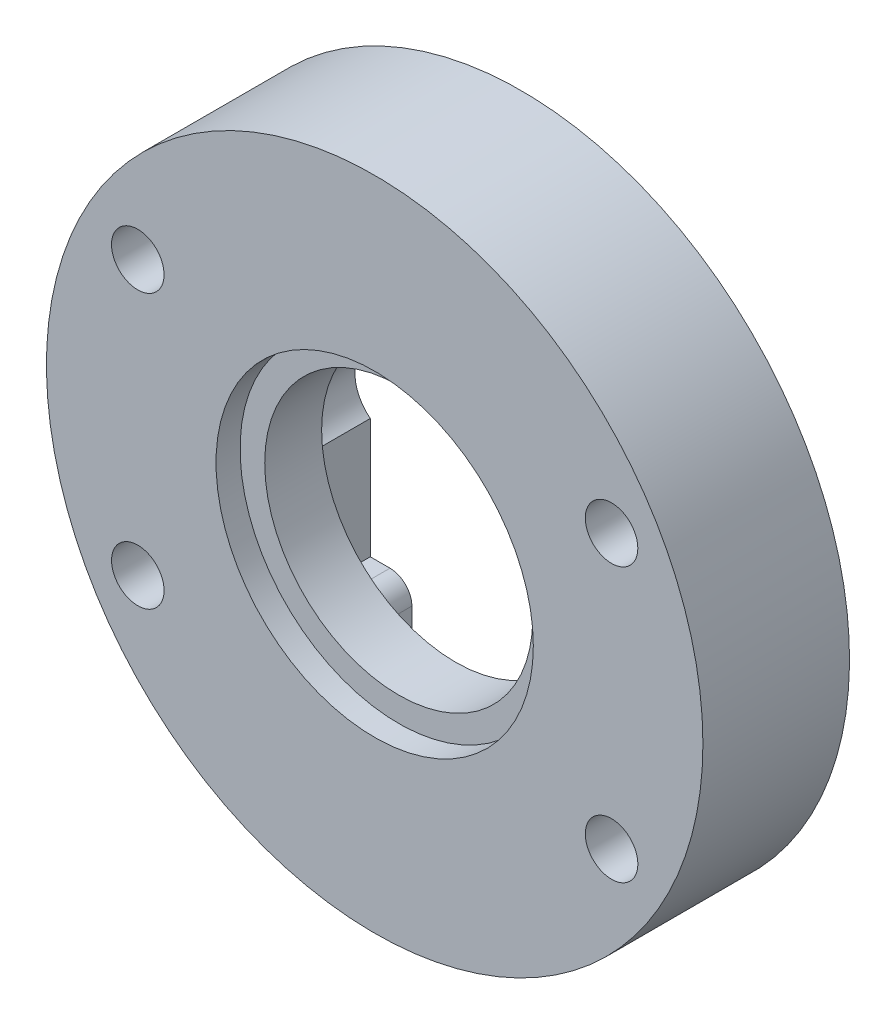
from build123d import *

# Parameters (mm, degrees)
EXTRUDE_1_DEPTH     = 3
CUT_EXTRUDE_4_DEPTH = 4
SKETCH_12_R         = 15
SKETCH_12_R_2       = 6.125
EXTRUDE_2_DEPTH     = 2.6
SKETCH_13_R         = 15
SKETCH_13_R_2       = 7.25
EXTRUDE_3_DEPTH     = 1.1
SKETCH_14_R         = 1.2
CUT_EXTRUDE_5_DEPTH = 7.7
FILLET_1_R          = 1


with BuildPart() as part:
    # 스케치1 → 보스-돌출1 (new body)
    with BuildSketch(Plane.XY):
        with BuildLine():
            Line((-5, -6.9), (-6.9, -6.9))
            Line((-6.9, -6.9), (-6.9, 6.9))
            Line((-6.9, 6.9), (6.9, 6.9))
            Line((6.9, 6.9), (6.9, -6.9))
            Line((6.9, -6.9), (5, -6.9))
            Line((5, -6.9), (5, -14.142135624))
            ThreePointArc((5, -14.142135624), (0, 15), (-5, -14.142135624))
            Line((-5, -14.142135624), (-5, -6.9))
        make_face()
    extrude(amount=EXTRUDE_1_DEPTH)

    # 스케치11 → 컷-돌출4 (cut, through all)
    with BuildSketch(Plane.XY.offset(3)):
        with BuildLine():
            Line((5.8, -1.8), (-5.8, -1.8))
            ThreePointArc((-5.8, -1.8), (-7.6, 0), (-5.8, 1.8))
            Line((-5.8, 1.8), (5.8, 1.8))
            ThreePointArc((5.8, 1.8), (7.6, 0), (5.8, -1.8))
        make_face()
    extrude(amount=-CUT_EXTRUDE_4_DEPTH, mode=Mode.SUBTRACT)

    # 스케치12 → 보스-돌출2 (add)
    with BuildSketch(Plane.XY.offset(3)):
        Circle(SKETCH_12_R)
        Circle(SKETCH_12_R_2, mode=Mode.SUBTRACT)
    extrude(amount=EXTRUDE_2_DEPTH)

    # 스케치13 → 보스-돌출3 (add)
    with BuildSketch(Plane.XY.offset(5.6)):
        Circle(SKETCH_13_R)
        Circle(SKETCH_13_R_2, mode=Mode.SUBTRACT)
    extrude(amount=EXTRUDE_3_DEPTH)

    # 스케치14 → 컷-돌출5 (cut, through all)
    with BuildSketch(Plane.XY.offset(6.7)):
        with Locations((10.825317547, 6.25)):
            Circle(SKETCH_14_R)
        with Locations((-10.825317547, 6.25)):
            Circle(SKETCH_14_R)
        with Locations((10.825317547, -6.25)):
            Circle(SKETCH_14_R)
        with Locations((-10.825317547, -6.25)):
            Circle(SKETCH_14_R)
    extrude(amount=-CUT_EXTRUDE_5_DEPTH, mode=Mode.SUBTRACT)

    # 필렛1
    fillet_1_edges = [part.edges().sort_by_distance(p)[0] for p in [
        (-5, -6.9, 1.5),
        (5, -6.9, 1.5),
    ]]
    fillet(fillet_1_edges, radius=FILLET_1_R)


solid = part.part
